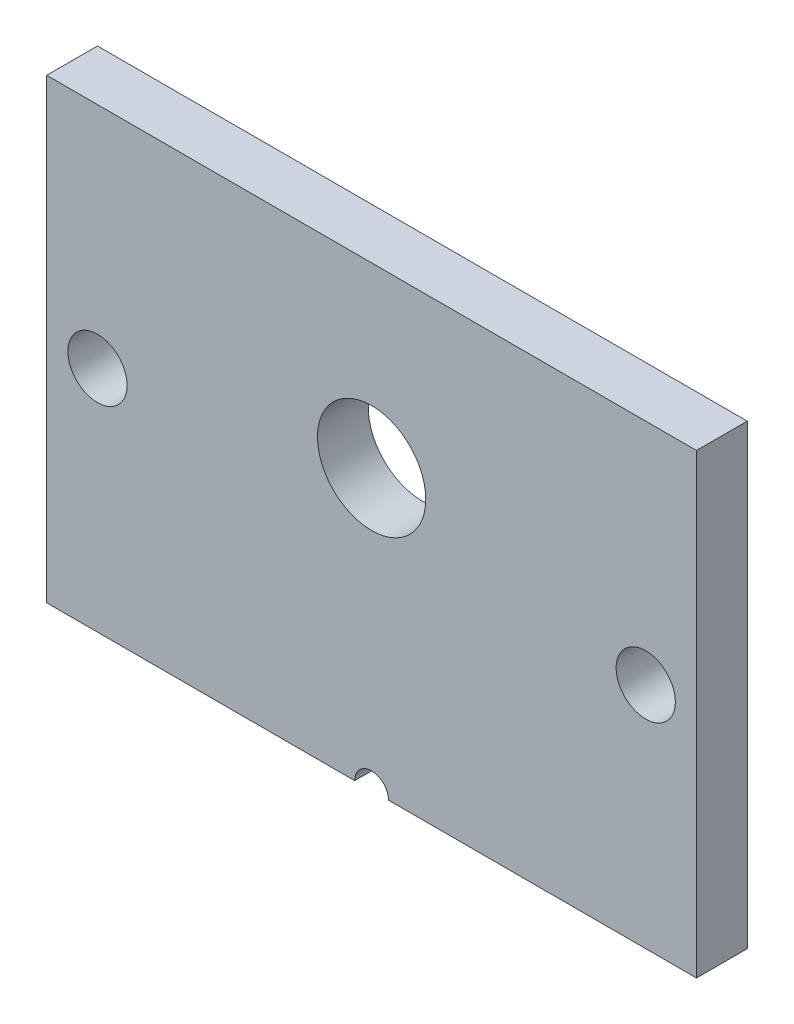
from build123d import *

# Parameters (mm, degrees)
SKETCH_1_W          = 38.4
SKETCH_1_H          = 27
EXTRUDE_1_DEPTH     = 3
SKETCH_2_R          = 1.75
CUT_EXTRUDE_1_DEPTH = 4
SKETCH_3_R          = 3.2
CUT_EXTRUDE_2_DEPTH = 4
SKETCH_4_R          = 1
CUT_EXTRUDE_3_DEPTH = 4


with BuildPart() as part:
    # ｽｹｯﾁ1 → ﾎﾞｽ - 押し出し1 (new body)
    with BuildSketch(Plane.XY):
        Rectangle(SKETCH_1_W, SKETCH_1_H)
    extrude(amount=EXTRUDE_1_DEPTH)

    # ｽｹｯﾁ2 → ｶｯﾄ - 押し出し1 (cut, through all)
    with BuildSketch(Plane.XY.offset(3)):
        with Locations((16.2, 0)):
            Circle(SKETCH_2_R)
        with Locations((-16.2, 0)):
            Circle(SKETCH_2_R)
    extrude(amount=-CUT_EXTRUDE_1_DEPTH, mode=Mode.SUBTRACT)

    # ｽｹｯﾁ3 → ｶｯﾄ - 押し出し2 (cut, through all)
    with BuildSketch(Plane.XY.offset(3)):
        with Locations((0, 3)):
            Circle(SKETCH_3_R)
    extrude(amount=-CUT_EXTRUDE_2_DEPTH, mode=Mode.SUBTRACT)

    # ｽｹｯﾁ4 → ｶｯﾄ - 押し出し3 (cut, through all)
    with BuildSketch(Plane.XY.offset(3)):
        with Locations((0, -13.5)):
            Circle(SKETCH_4_R)
    extrude(amount=-CUT_EXTRUDE_3_DEPTH, mode=Mode.SUBTRACT)


solid = part.part
